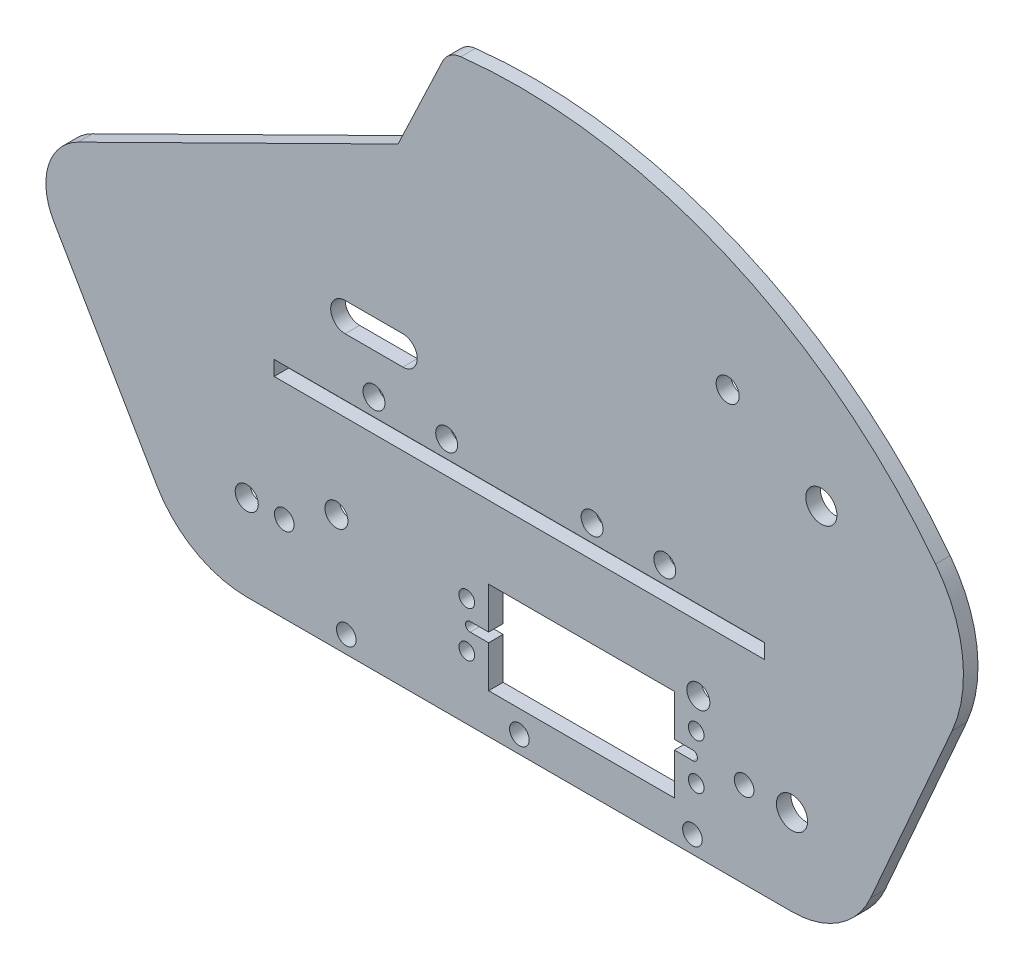
from build123d import *

# Parameters (mm, degrees)
SKETCH1_R           = 3.429
SKETCH1_R_2         = 2.54
BOSS_EXTRUDE1_DEPTH = 3.2004
SKETCH2_R           = 2.413
CUT_EXTRUDE1_DEPTH  = 3.2004
SKETCH5_R           = 1.7272
SKETCH5_W           = 40.894
SKETCH5_H           = 20.32
CUT_EXTRUDE3_DEPTH  = 4.2004
CUT_EXTRUDE5_DEPTH  = 3.2004
SKETCH6_R           = 2.54
CUT_EXTRUDE4_DEPTH  = 4.2004
SKETCH9_R           = 2.159
CUT_EXTRUDE6_DEPTH  = 3.2004
SKETCH10_W          = 107.95
SKETCH10_H          = 3.2512
CUT_EXTRUDE7_DEPTH  = 3.2004
SKETCH11_R          = 3.429
SKETCH11_R_2        = 2.54
CUT_EXTRUDE8_DEPTH  = 3.2004
CUT_EXTRUDE9_DEPTH  = 3.2004
SKETCH15_R          = 2.159
CUT_EXTRUDE10_DEPTH = 3.2004
BOSS_EXTRUDE2_DEPTH = 3.2004
FILLET1_R           = 5.08
CUT_EXTRUDE11_DEPTH = 3.2004
CUT_EXTRUDE12_DEPTH = 3.2004
FILLET2_R           = 12.7


with BuildPart() as part:
    # Sketch1 → Boss-Extrude1 (new body)
    with BuildSketch(Plane.XY):
        with BuildLine():
            Line((0, 0), (120.015, 0))
            ThreePointArc((120.015, 0), (130.351788396, 3.075697789), (137.325636158, 11.302152592))
            Line((137.325636158, 11.302152592), (155.2575, 52.11572))
            ThreePointArc((155.2575, 52.11572), (157.54731739, 67.602183396), (151.630955452, 82.09599151))
            ThreePointArc((151.630955452, 82.09599151), (60.0075, 127.266502568), (-31.615955452, 82.09599151))
            ThreePointArc((-31.615955452, 82.09599151), (-37.53231739, 67.602183396), (-35.2425, 52.11572))
            Line((-35.2425, 52.11572), (-17.310636158, 11.302152592))
            ThreePointArc((-17.310636158, 11.302152592), (-10.336788396, 3.075697789), (0, 0))
        make_face()
        with Locations((120.015, 18.90776)):
            Circle(SKETCH1_R, mode=Mode.SUBTRACT)
        with Locations((0, 18.90776)):
            Circle(SKETCH1_R_2, mode=Mode.SUBTRACT)
        with Locations((19.734727626, 25.566426992)):
            Circle(SKETCH1_R_2, mode=Mode.SUBTRACT)
    extrude(amount=BOSS_EXTRUDE1_DEPTH)

    # Sketch2 → Cut-Extrude1 (cut)
    with BuildSketch(Plane(origin=(0, 0, 0), x_dir=(-1, 0, 0), z_dir=(0, 0, -1))):
        with Locations((-92.0115, 52.11572)):
            Circle(SKETCH2_R)
        with Locations((-76.0095, 52.11572)):
            Circle(SKETCH2_R)
        with Locations((-44.0055, 52.11572)):
            Circle(SKETCH2_R)
        with Locations((-28.0035, 52.11572)):
            Circle(SKETCH2_R)
    extrude(amount=-CUT_EXTRUDE1_DEPTH, mode=Mode.SUBTRACT)

    # Sketch5 → Cut-Extrude3 (cut, through all)
    with BuildSketch(Plane(origin=(0, 0, 0), x_dir=(-1, 0, 0), z_dir=(0, 0, -1))):
        with Locations((-98.932021353, 23.907759967)):
            Circle(SKETCH5_R)
        with Locations((-48.432021353, 13.907760033)):
            Circle(SKETCH5_R)
        with Locations((-48.432021353, 23.907759967)):
            Circle(SKETCH5_R)
        with Locations((-98.932021353, 13.907760033)):
            Circle(SKETCH5_R)
        with Locations((-73.682021353, 18.90776)):
            Rectangle(SKETCH5_W, SKETCH5_H)
    extrude(amount=-CUT_EXTRUDE3_DEPTH, mode=Mode.SUBTRACT)

    # Sketch7 → Cut-Extrude5 (cut)
    with BuildSketch(Plane(origin=(0, 0, 0), x_dir=(-1, 0, 0), z_dir=(0, 0, -1))):
        with BuildLine():
            Line((-98.193021353, 19.92376), (-94.129021353, 19.92376))
            Line((-94.129021353, 19.92376), (-94.129021353, 17.89176))
            Line((-94.129021353, 17.89176), (-98.193021353, 17.89176))
            ThreePointArc((-98.193021353, 17.89176), (-99.209021353, 18.90776), (-98.193021353, 19.92376))
        make_face()
        with BuildLine():
            Line((-53.235021353, 19.92376), (-49.171021353, 19.92376))
            ThreePointArc((-49.171021353, 19.92376), (-48.155021353, 18.90776), (-49.171021353, 17.89176))
            Line((-49.171021353, 17.89176), (-53.235021353, 17.89176))
            Line((-53.235021353, 17.89176), (-53.235021353, 19.92376))
        make_face()
    extrude(amount=-CUT_EXTRUDE5_DEPTH, mode=Mode.SUBTRACT)

    # Sketch6 → Cut-Extrude4 (cut, through all)
    with BuildSketch(Plane(origin=(0, 0, 0), x_dir=(-1, 0, 0), z_dir=(0, 0, -1))):
        with Locations((-99.400822485, 30.809360937)):
            Circle(SKETCH6_R)
    extrude(amount=-CUT_EXTRUDE4_DEPTH, mode=Mode.SUBTRACT)

    # Sketch9 → Cut-Extrude6 (cut)
    with BuildSketch(Plane.XY.offset(3.2004)):
        with Locations((21.9075, 3.81)):
            Circle(SKETCH9_R)
        with Locations((60.0075, 3.81)):
            Circle(SKETCH9_R)
        with Locations((98.1075, 3.81)):
            Circle(SKETCH9_R)
    extrude(amount=-CUT_EXTRUDE6_DEPTH, mode=Mode.SUBTRACT)

    # Sketch10 → Cut-Extrude7 (cut)
    with BuildSketch(Plane.XY.offset(3.2004)):
        with Locations((60.0075, 46.68012)):
            Rectangle(SKETCH10_W, SKETCH10_H)
    extrude(amount=-CUT_EXTRUDE7_DEPTH, mode=Mode.SUBTRACT)

    # Sketch11 → Cut-Extrude8 (cut)
    with BuildSketch(Plane.XY.offset(3.2004)):
        with Locations((126.474462556, 80.535782848)):
            Circle(SKETCH11_R)
        with Locations((105.860285087, 92.437383759)):
            Circle(SKETCH11_R_2)
    extrude(amount=-CUT_EXTRUDE8_DEPTH, mode=Mode.SUBTRACT)

    # Sketch14 → Cut-Extrude9 (cut)
    with BuildSketch(Plane(origin=(0, 0, 0), x_dir=(-1, 0, 0), z_dir=(0, 0, -1))):
        with BuildLine():
            Line((-44.300963253, 126.193661773), (-33.301235987, 102.993397816))
            Line((-33.301235987, 102.993397816), (25.933073592, 73.679154431))
            Line((25.933073592, 73.679154431), (30.688377769, 83.288038279))
            ThreePointArc((30.688377769, 83.288038279), (-2.643821722, 112.015909409), (-44.300963253, 126.193661773))
        make_face()
    extrude(amount=-CUT_EXTRUDE9_DEPTH, mode=Mode.SUBTRACT)

    # Sketch15 → Cut-Extrude10 (cut)
    with BuildSketch(Plane.XY.offset(3.2004)):
        with Locations((8.255, 18.90776)):
            Circle(SKETCH15_R)
        with Locations((109.47654, 18.90776)):
            Circle(SKETCH15_R)
    extrude(amount=-CUT_EXTRUDE10_DEPTH, mode=Mode.SUBTRACT)

    # Sketch16 → Boss-Extrude2 (add)
    with BuildSketch(Plane.XY.offset(3.2004)):
        with BuildLine():
            Line((-45.041102147, 54.757414103), (-19.827237301, 11.4051976))
            ThreePointArc((-19.827237301, 11.4051976), (-11.436759498, 3.05471175), (0, 0))
            ThreePointArc((0, 0), (-15.87467945, 35.815989499), (-25.933073592, 73.679154431))
            Line((-25.933073592, 73.679154431), (-33.949803194, 89.878291377))
            ThreePointArc((-33.949803194, 89.878291377), (-38.093703484, 85.921735268), (-42.068546328, 81.795372437))
            ThreePointArc((-42.068546328, 81.795372437), (-48.007013112, 68.765867356), (-45.041102147, 54.757414103))
        make_face()
    extrude(amount=-BOSS_EXTRUDE2_DEPTH)

    # Fillet1
    fillet1_edges = [part.edges().sort_by_distance(p)[0] for p in [
        (44.300963253, 126.193661773, 1.6002),
        (-33.949803194, 89.878291377, 1.6002),
    ]]
    fillet(fillet1_edges, radius=FILLET1_R)

    # Sketch17 → Cut-Extrude11 (cut)
    with BuildSketch(Plane(origin=(0, 0, 0), x_dir=(-1, 0, 0), z_dir=(0, 0, -1))):
        with BuildLine():
            Line((-34.3535, 67.35572), (-21.6535, 67.35572))
            ThreePointArc((-21.6535, 67.35572), (-18.4785, 64.18072), (-21.6535, 61.00572))
            Line((-21.6535, 61.00572), (-34.3535, 61.00572))
            ThreePointArc((-34.3535, 61.00572), (-37.5285, 64.18072), (-34.3535, 67.35572))
        make_face()
    extrude(amount=-CUT_EXTRUDE11_DEPTH, mode=Mode.SUBTRACT)

    # Sketch18 → Cut-Extrude12 (cut)
    with BuildSketch(Plane(origin=(0, 0, 0), x_dir=(-1, 0, 0), z_dir=(0, 0, -1))):
        Polygon((25.933073592, 73.679154431), (45.392963589, 113.00110224), (91.414081971, 83.705991697), (68.906880725, 52.412009588), align=None)
    extrude(amount=-CUT_EXTRUDE12_DEPTH, mode=Mode.SUBTRACT)

    # Fillet2
    fillet2_edges = [part.edges().sort_by_distance(p)[0] for p in [
        (-47.882876097, 62.816499705, 1.6002),
    ]]
    fillet(fillet2_edges, radius=FILLET2_R)


solid = part.part
